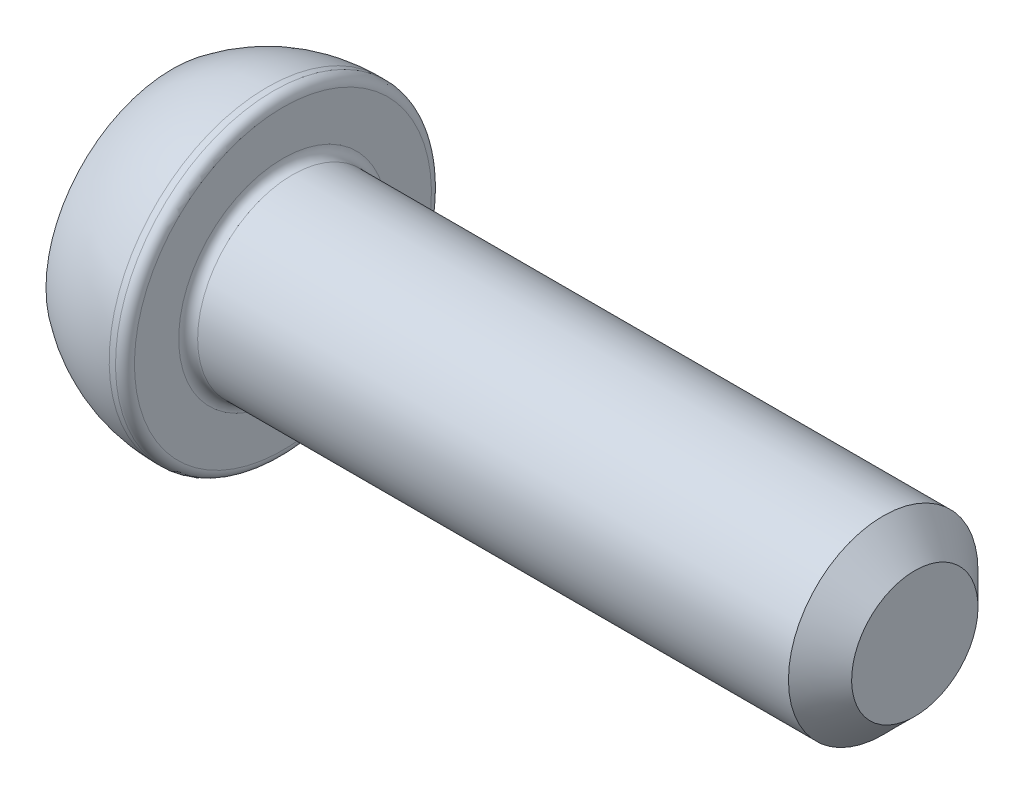
from build123d import *

# Parameters (mm, degrees)
CUT_EXTRUDE_1_DEPTH = 2
FILLET_1_R          = 0.3
CHAMFER_1_SIZE      = 1


with BuildPart() as part:
    # Эскиз1 → Повернуть1 (revolve)
    with BuildSketch(Plane.XY):
        with BuildLine():
            Line((0, 0), (0, 4))
            ThreePointArc((0, 4), (1.41886117, 4.74341649), (3, 5))
            Line((3, 5), (3.5, 5))
            Line((3.5, 5), (3.5, 3))
            Line((3.5, 3), (23.5, 3))
            Line((23.5, 3), (23.5, 0))
            Line((23.5, 0), (0, 0))
        make_face()
    revolve(axis=Axis((23.5, 0, 0), (-1, 0, 0)))

    # Эскиз2 → Вырез-Вытянуть1 (cut)
    with BuildSketch(Plane.ZY):
        Polygon((1.154700538, 2), (-1.154700538, 2), (-2.309401077, 0), (-1.154700538, -2), (1.154700538, -2), (2.309401077, 0), align=None)
    extrude(amount=-CUT_EXTRUDE_1_DEPTH, mode=Mode.SUBTRACT)

    # Скругление1
    fillet_1_edges = [part.edges().sort_by_distance(p)[0] for p in [
        (3.5, -3, 0),
        (3.5, -5, 0),
    ]]
    fillet(fillet_1_edges, radius=FILLET_1_R)

    # Фаска1
    chamfer_1_edges = [part.edges().sort_by_distance(p)[0] for p in [
        (23.5, -3, 0),
    ]]
    chamfer(chamfer_1_edges, length=CHAMFER_1_SIZE)


solid = part.part
